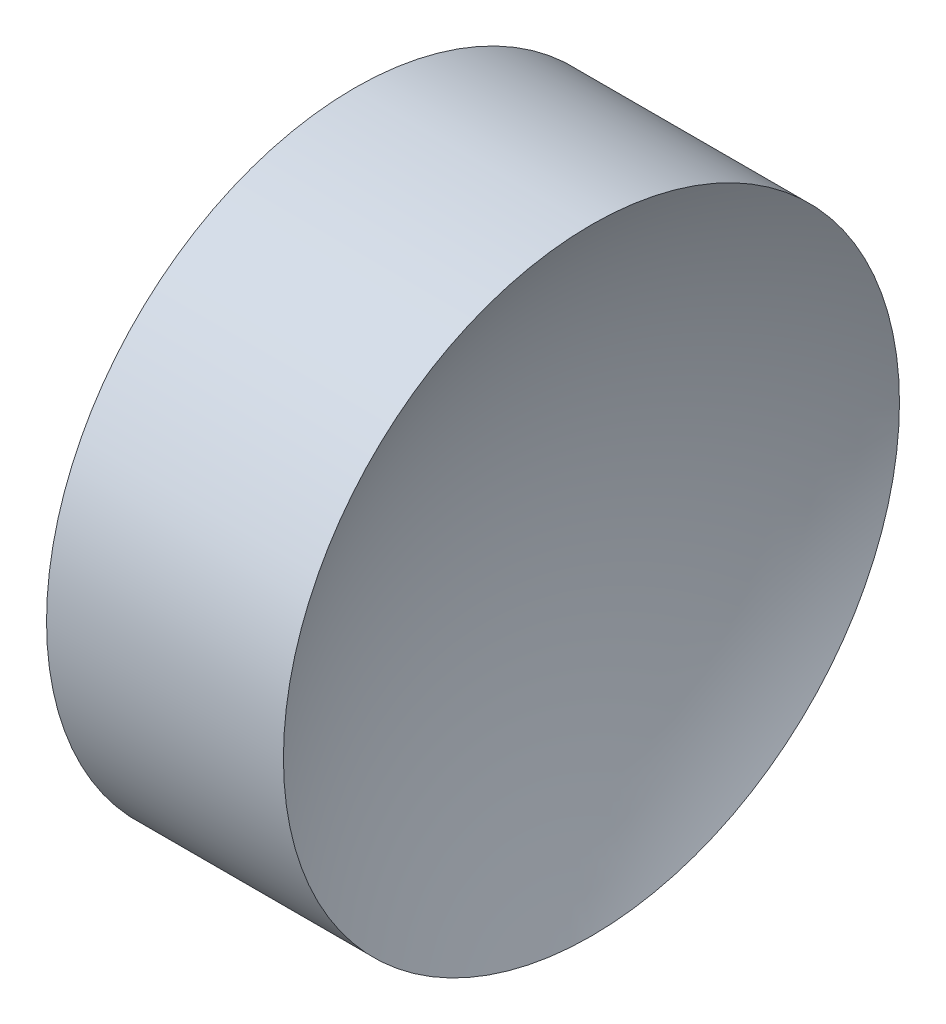
from build123d import *


with BuildPart() as part:
    # 草图1 → 旋转1 (revolve)
    with BuildSketch(Plane.XY, mode=Mode.PRIVATE) as revolve_1_sk:
        with BuildLine():
            Line((60.851599818, 32.611301436), (59.351599809, 32.611301436))
            ThreePointArc((59.351599809, 32.611301436), (58.931280936, 35.843791678), (57.698278106, 38.861301436))
            Line((57.698278106, 38.861301436), (60.101599818, 38.861301436))
            Line((60.101599818, 38.861301436), (62.504921521, 38.861301436))
            ThreePointArc((62.504921521, 38.861301436), (61.271918691, 35.843791678), (60.851599818, 32.611301436))
        make_face()
    revolve(revolve_1_sk.sketch.rotate(Axis((53.062326393, 32.611301436, 0), (1, 0, 0)), 90), axis=Axis((53.062326393, 32.611301436, 0), (1, 0, 0)))  # turned: the seam where the file's is


solid = part.part
